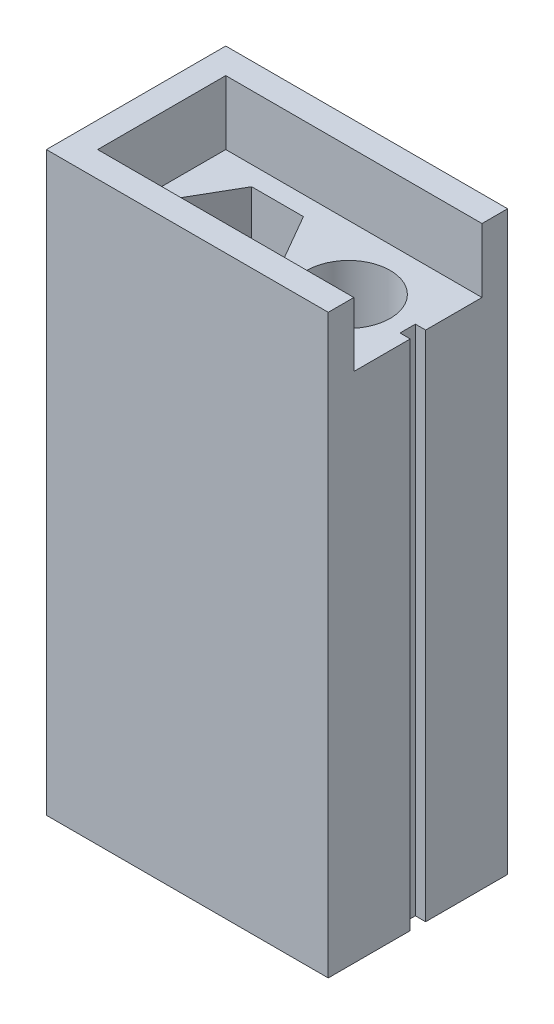
from build123d import *

# Parameters (mm, degrees)
SKETCH1_W           = 22
SKETCH1_H           = 14
BOSS_EXTRUDE1_DEPTH = 40
BOSS_EXTRUDE2_DEPTH = 5
SKETCH3_R           = 3.25
CUT_EXTRUDE1_DEPTH  = 41
SKETCH4_W           = 1.2
SKETCH4_H           = 40
CUT_EXTRUDE2_DEPTH  = 0.8


with BuildPart() as part:
    # Sketch1 → Boss-Extrude1 (new body)
    with BuildSketch(Plane(origin=(0, 0, 0), x_dir=(1, 0, 0), z_dir=(0, 1, 0))):
        with Locations((11, 7)):
            Rectangle(SKETCH1_W, SKETCH1_H)
    extrude(amount=BOSS_EXTRUDE1_DEPTH)

    # Sketch2 → Boss-Extrude2 (add)
    with BuildSketch(Plane(origin=(0, 40, 0), x_dir=(1, 0, 0), z_dir=(0, 1, 0))):
        Polygon((22, 0), (22, 2), (2, 2), (2, 12), (22, 12), (22, 14), (0, 14), (0, 0), align=None)
    extrude(amount=BOSS_EXTRUDE2_DEPTH)

    # Sketch3 → Cut-Extrude1 (cut, through all)
    with BuildSketch(Plane(origin=(0, 40, 0), x_dir=(1, 0, 0), z_dir=(0, 1, 0))):
        with Locations((16.582903769, 7)):
            Circle(SKETCH3_R)
        Polygon((11.582903769, 7), (9.562177826, 10.5), (5.520725942, 10.5), (3.5, 7), (5.520725942, 3.5), (9.562177826, 3.5), align=None)
    extrude(amount=-CUT_EXTRUDE1_DEPTH, mode=Mode.SUBTRACT)

    # Sketch4 → Cut-Extrude2 (cut)
    with BuildSketch(Plane(origin=(22, 0, 0), x_dir=(0, 0, -1), z_dir=(1, 0, 0))):
        with Locations((7, 20)):
            Rectangle(SKETCH4_W, SKETCH4_H)
    extrude(amount=-CUT_EXTRUDE2_DEPTH, mode=Mode.SUBTRACT)


solid = part.part
